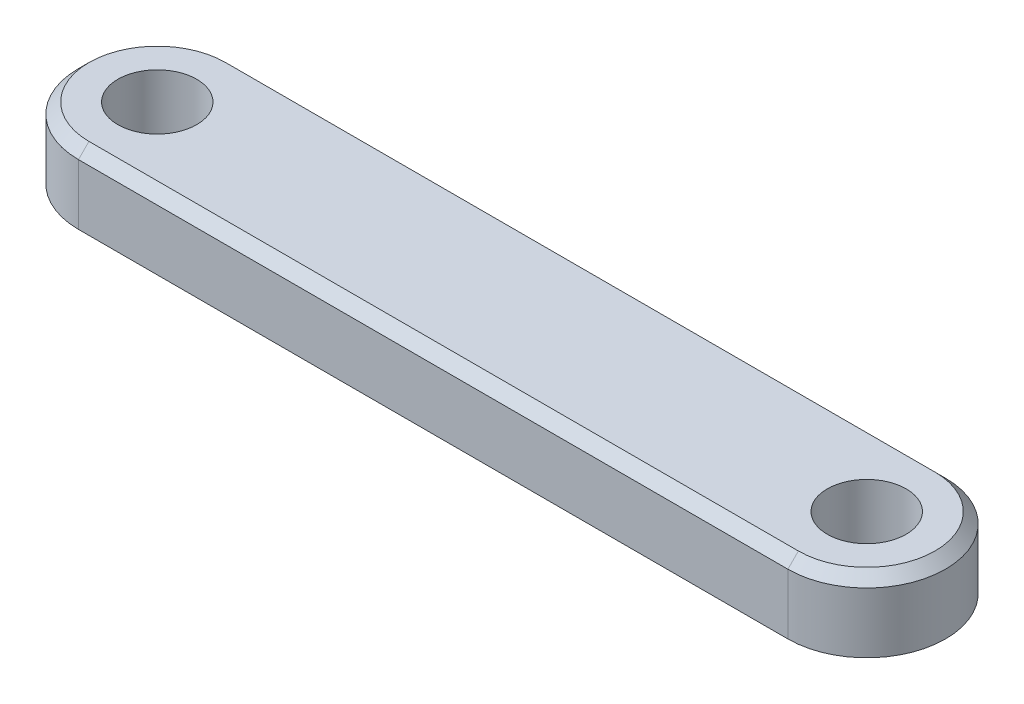
from build123d import *

# Parameters (mm, degrees)
SKETCH1_R           = 1.5
BOSS_EXTRUDE1_DEPTH = 1.35
CHAMFER1_SIZE       = 0.4


with BuildPart() as part:
    # Sketch1 → Boss-Extrude1 (new body, symmetric)
    with BuildSketch(Plane(origin=(0, 0, 0), x_dir=(1, 0, 0), z_dir=(0, 1, 0))):
        with BuildLine():
            Line((-13.5, 3), (13.5, 3))
            ThreePointArc((13.5, 3), (16.5, 0), (13.5, -3))
            Line((13.5, -3), (-13.5, -3))
            ThreePointArc((-13.5, -3), (-16.5, 0), (-13.5, 3))
        make_face()
        with Locations((-13.5, 0)):
            Circle(SKETCH1_R, mode=Mode.SUBTRACT)
        with Locations((13.5, 0)):
            Circle(SKETCH1_R, mode=Mode.SUBTRACT)
    extrude(amount=BOSS_EXTRUDE1_DEPTH, both=True)

    # Chamfer1
    chamfer1_edges = [part.edges().sort_by_distance(p)[0] for p in [
        (16.5, 1.35, 0),
        (0, 1.35, -3),
        (-16.5, 1.35, 0),
        (0, 1.35, 3),
    ]]
    chamfer(chamfer1_edges, length=CHAMFER1_SIZE)


solid = part.part
